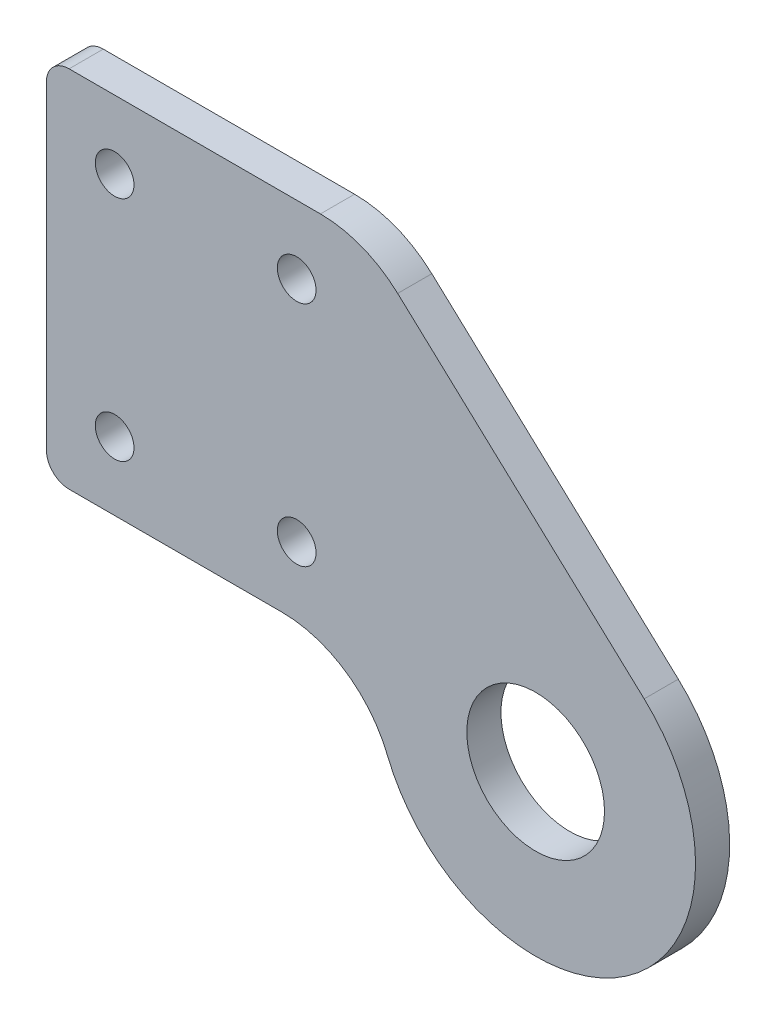
from build123d import *

# Parameters (mm, degrees)
ESQUISSE1_R        = 3.025
ESQUISSE1_R_2      = 0.85
BOSS_EXTRU_1_DEPTH = 0.75
CONG_1_R           = 5
CONG_2_R           = 1


with BuildPart() as part:
    # Esquisse1 → Boss.-Extru.1 (new body, symmetric)
    with BuildSketch(Plane.XY):
        with BuildLine():
            Line((-7.5, 16.5), (4.768672746, 5.158525491))
            ThreePointArc((4.768672746, 5.158525491), (2.584220944, -6.532413575), (-7.007183814, 0.5))
            Line((-7.007183814, 0.5), (-7.5, 0.5))
            Line((-7.5, 0.5), (-21.5, 0.5))
            Line((-21.5, 0.5), (-21.5, 16.5))
            Line((-21.5, 16.5), (-7.5, 16.5))
        make_face()
        Circle(ESQUISSE1_R, mode=Mode.SUBTRACT)
        with Locations((-18.5, 13.5)):
            Circle(ESQUISSE1_R_2, mode=Mode.SUBTRACT)
        with Locations((-10.5, 13.5)):
            Circle(ESQUISSE1_R_2, mode=Mode.SUBTRACT)
        with Locations((-10.5, 3.5)):
            Circle(ESQUISSE1_R_2, mode=Mode.SUBTRACT)
        with Locations((-18.5, 3.5)):
            Circle(ESQUISSE1_R_2, mode=Mode.SUBTRACT)
    extrude(amount=BOSS_EXTRU_1_DEPTH, both=True)

    # Congé1
    cong_1_edges = [part.edges().sort_by_distance(p)[0] for p in [
        (-7.5, 16.5, 0),
        (-7.007183814, 0.5, 0),
    ]]
    fillet(cong_1_edges, radius=CONG_1_R)

    # Congé2
    cong_2_edges = [part.edges().sort_by_distance(p)[0] for p in [
        (-21.5, 16.5, 0),
        (-21.5, 0.5, 0),
    ]]
    fillet(cong_2_edges, radius=CONG_2_R)


solid = part.part
